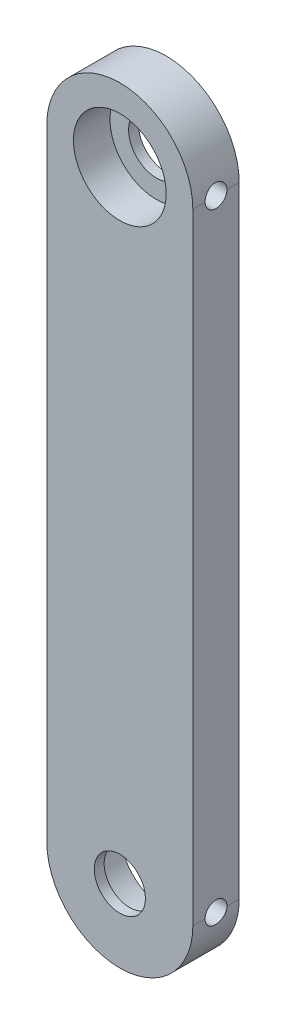
from build123d import *

# Parameters (mm, degrees)
SALIENTE_EXTRUIR1_DEPTH = 6.35
CROQUIS2_R              = 6.35
CORTAR_EXTRUIR1_DEPTH   = 5
CROQUIS3_R              = 3.8
CORTAR_EXTRUIR2_DEPTH   = 54.677276384
CROQUIS6_R              = 1.5
CORTAR_EXTRUIR5_DEPTH   = 5
CROQUIS7_R              = 6.35
CORTAR_EXTRUIR6_DEPTH   = 5
CROQUIS8_R              = 3.5
CORTAR_EXTRUIR7_DEPTH   = 5
CROQUIS9_R              = 1.5
CORTAR_EXTRUIR8_DEPTH   = 5


with BuildPart() as part:
    # Croquis1 → Saliente-Extruir1 (new body)
    with BuildSketch(Plane.XY):
        with BuildLine():
            Line((10, 42.5), (10, -42.5))
            ThreePointArc((10, -42.5), (0, -52.5), (-10, -42.5))
            Line((-10, -42.5), (-10, 42.5))
            ThreePointArc((-10, 42.5), (0, 52.5), (10, 42.5))
        make_face()
    extrude(amount=SALIENTE_EXTRUIR1_DEPTH)

    # Croquis2 → Cortar-Extruir1 (cut)
    with BuildSketch(Plane.XY.offset(6.35)):
        with Locations((0, 42.5)):
            Circle(CROQUIS2_R)
    extrude(amount=-CORTAR_EXTRUIR1_DEPTH, mode=Mode.SUBTRACT)

    # Croquis3 → Cortar-Extruir2 (cut, through all)
    with BuildSketch(Plane.XY.offset(1.35)):
        with Locations((0, 42.5)):
            Circle(CROQUIS3_R)
    extrude(amount=-CORTAR_EXTRUIR2_DEPTH, mode=Mode.SUBTRACT)

    # Croquis6 → Cortar-Extruir5 (cut)
    with BuildSketch(Plane(origin=(10, 0, 0), x_dir=(0, 0, -1), z_dir=(1, 0, 0))):
        with Locations((-3.175, 42.5)):
            Circle(CROQUIS6_R)
    extrude(amount=-CORTAR_EXTRUIR5_DEPTH, mode=Mode.SUBTRACT)

    # Croquis7 → Cortar-Extruir6 (cut)
    with BuildSketch(Plane(origin=(0, 0, 0), x_dir=(-1, 0, 0), z_dir=(0, 0, -1))):
        with Locations((0, -42.5)):
            Circle(CROQUIS7_R)
    extrude(amount=-CORTAR_EXTRUIR6_DEPTH, mode=Mode.SUBTRACT)

    # Croquis8 → Cortar-Extruir7 (cut)
    with BuildSketch(Plane(origin=(0, 0, 5), x_dir=(-1, 0, 0), z_dir=(0, 0, -1))):
        with Locations((0, -42.5)):
            Circle(CROQUIS8_R)
    extrude(amount=-CORTAR_EXTRUIR7_DEPTH, mode=Mode.SUBTRACT)

    # Croquis9 → Cortar-Extruir8 (cut)
    with BuildSketch(Plane(origin=(10, 0, 0), x_dir=(0, 0, -1), z_dir=(1, 0, 0))):
        with Locations((-3.175, -42.5)):
            Circle(CROQUIS9_R)
    extrude(amount=-CORTAR_EXTRUIR8_DEPTH, mode=Mode.SUBTRACT)


solid = part.part
